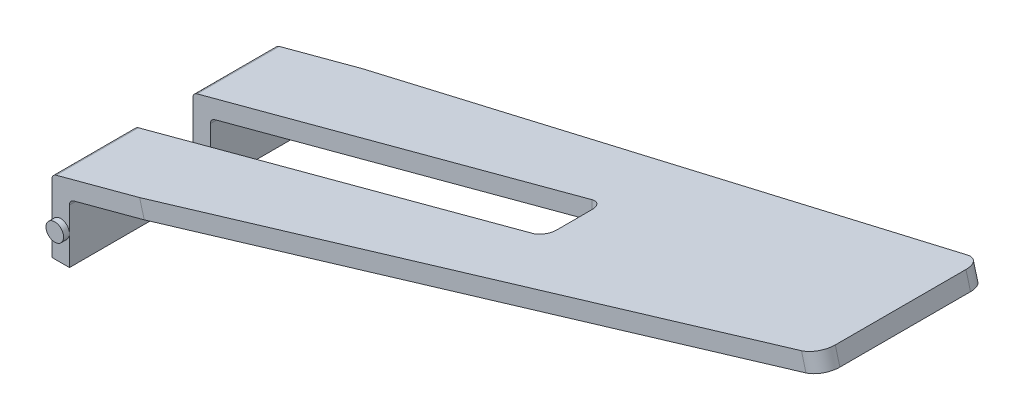
from build123d import *

# Parameters (mm, degrees)
BOSS_EXTRUDE1_DEPTH      = 3.8
CHAMFER1_SIZE            = 0.5
CHAMFER1_SIZE2           = 11.451882774
SKETCH3_R                = 0.15
BOSS_EXTRUDE2_DEPTH      = 0.1
BOSS_EXTRUDE2_DEPTH_BACK = 3.9
SKETCH4_W                = 7
SKETCH4_H                = 1
CUT_EXTRUDE2_DEPTH       = 10
FILLET1_R                = 0.1
FILLET2_R                = 0.3
FILLET3_R                = 0.2


with BuildPart() as part:
    # Sketch1 → Boss-Extrude1 (new body)
    with BuildSketch(Plane.XY):
        Polygon((0, 0), (0, 1.230198096), (12.557035742, 4.594845683), (12.634681455, 4.305067935), (0.3, 1), (0.3, 0), align=None)
    extrude(amount=BOSS_EXTRUDE1_DEPTH)

    # Chamfer1
    chamfer1_edges = [part.edges().sort_by_distance(p)[0] for p in [
        (12.595858599, 4.449956809, 3.8),
        (12.595858599, 4.449956809, 0),
    ]]
    chamfer1_side = [part.faces().sort_by_distance(p)[0] for p in [
        (12.595858599, 4.449956809, 1.9),
    ]]
    chamfer(chamfer1_edges, length=CHAMFER1_SIZE, length2=CHAMFER1_SIZE2, reference=chamfer1_side[0])

    # Sketch3 → Boss-Extrude2 (add, two sides)
    with BuildSketch(Plane.XY.offset(3.8)) as boss_extrude2_sk:
        with Locations((0.15, 0.5)):
            Circle(SKETCH3_R)
    extrude(amount=BOSS_EXTRUDE2_DEPTH)
    extrude(boss_extrude2_sk.sketch, amount=-BOSS_EXTRUDE2_DEPTH_BACK)

    # Sketch4 → Cut-Extrude2 (cut)
    with BuildSketch(Plane.XZ):
        with Locations((3.5, 1.9)):
            Rectangle(SKETCH4_W, SKETCH4_H)
    extrude(amount=-CUT_EXTRUDE2_DEPTH, mode=Mode.SUBTRACT)

    # Fillet1
    fillet1_edges = [part.edges().sort_by_distance(p)[0] for p in [
        (0, 1.230198096, 3.1),
        (0.3, 1, 3.1),
        (0, 1.230198096, 0.7),
        (0.3, 1, 0.7),
    ]]
    fillet(fillet1_edges, radius=FILLET1_R)

    # Fillet2
    fillet2_edges = [part.edges().sort_by_distance(p)[0] for p in [
        (12.595858599, 4.449956809, 0.5),
        (12.595858599, 4.449956809, 3.3),
    ]]
    fillet(fillet2_edges, radius=FILLET2_R)

    # Fillet3
    fillet3_edges = [part.edges().sort_by_distance(p)[0] for p in [
        (7, 2.950551016, 2.4),
        (7, 2.950551016, 1.4),
    ]]
    fillet(fillet3_edges, radius=FILLET3_R)


solid = part.part
